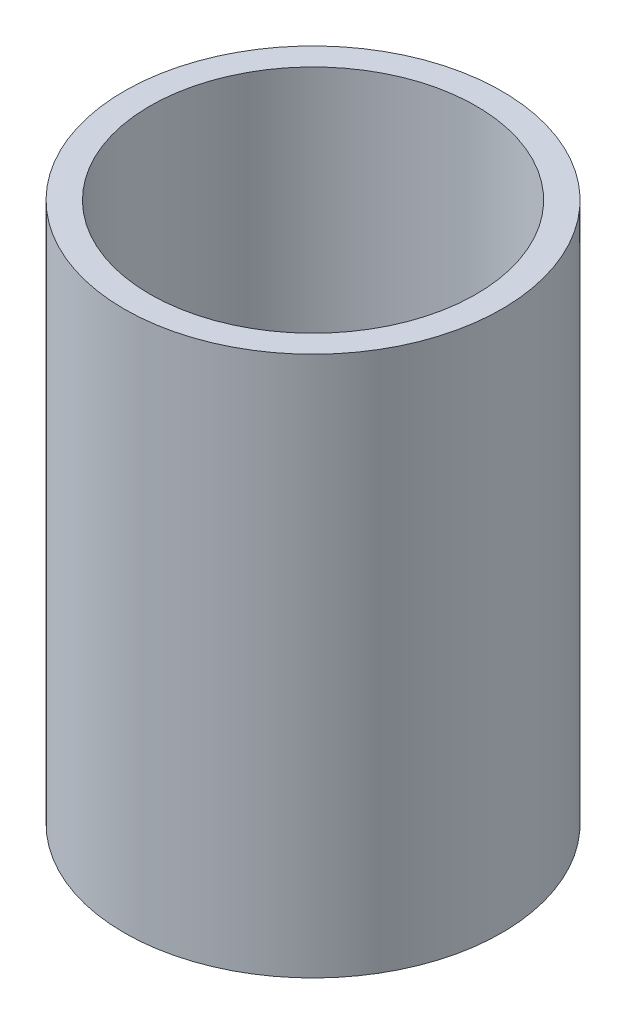
from build123d import *

# Parameters (mm, degrees)
SKETCH1_W = 6.35
SKETCH1_H = 133.35


with BuildPart() as part:
    # Sketch1 → Revolve1 (revolve)
    with BuildSketch(Plane.XY):
        with Locations((-43.434, -21.057365567)):
            Rectangle(SKETCH1_W, SKETCH1_H)
    revolve(axis=Axis((0, 55, 0), (0, -1, 0)))


solid = part.part
